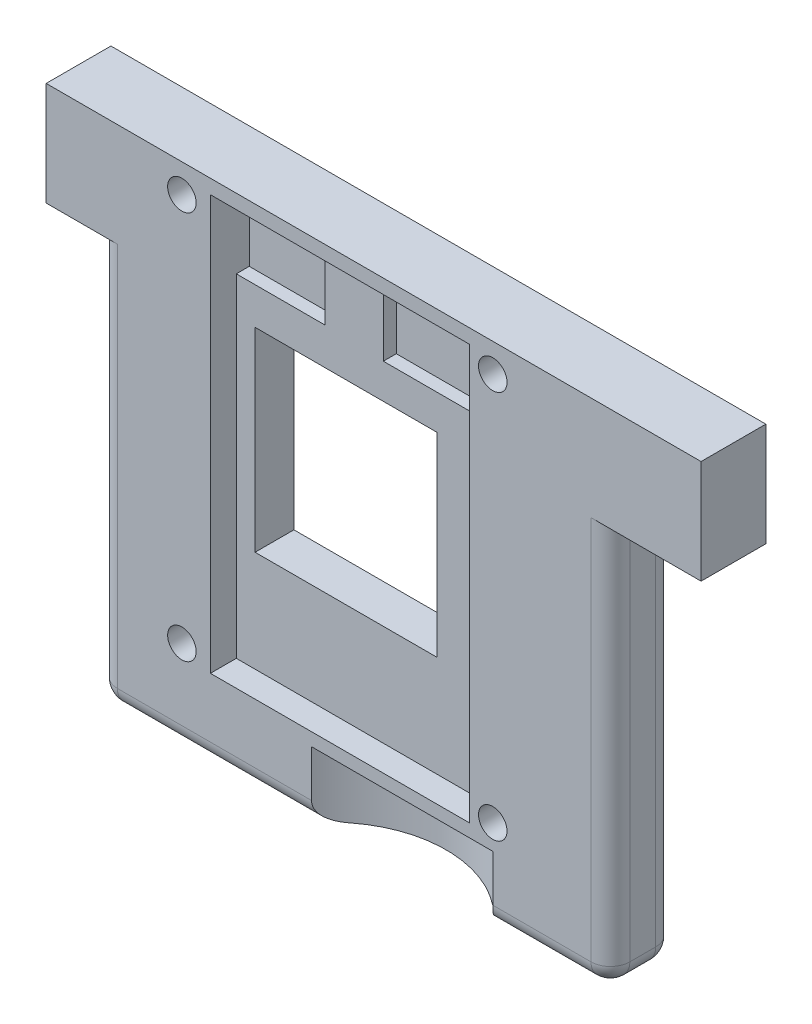
from build123d import *

# Parameters (mm, degrees)
SKETCH1_W               = 19.78
SKETCH1_H               = 22
BOSS_EXTRUDE1_DEPTH     = 2.5
SKETCH2_R               = 0.55
CUT_EXTRUDE1_DEPTH      = 2.5
SKETCH3_W               = 7.014228963
SKETCH3_H               = 7.519558389
CUT_EXTRUDE2_DEPTH      = 2.5
SKETCH4_W               = 10
SKETCH4_H               = 16
CUT_EXTRUDE3_DEPTH      = 1
SKETCH5_W               = 4.325292028
SKETCH5_H               = 2.74046394
SKETCH5_W_2             = 3.425085756
SKETCH5_H_2             = 3.145892333
CUT_EXTRUDE4_DEPTH      = 0.5
SKETCH6_R               = 4.45
CUT_EXTRUDE5_DEPTH      = 1.5
CUT_EXTRUDE5_DEPTH_BACK = 1.1
SKETCH7_W               = 19.78
SKETCH7_H               = 2.5
CUT_EXTRUDE6_DEPTH      = 2.4
SKETCH8_W               = 3.5
SKETCH8_H               = 4
SKETCH8_W_2             = 2
BOSS_EXTRUDE2_DEPTH     = 2.5
FILLET1_R               = 0.75


with BuildPart() as part:
    # Sketch1 → Boss-Extrude1 (new body)
    with BuildSketch(Plane.XY):
        with Locations((16.80685162, -7.939657117)):
            Rectangle(SKETCH1_W, SKETCH1_H)
    extrude(amount=BOSS_EXTRUDE1_DEPTH)

    # Sketch2 → Cut-Extrude1 (cut)
    with BuildSketch(Plane.XY.offset(2.5)):
        with Locations((22.156215749, -0.440049881)):
            Circle(SKETCH2_R)
        with Locations((22.156215749, -15.440049881)):
            Circle(SKETCH2_R)
        with Locations((10.156215749, -15.440049881)):
            Circle(SKETCH2_R)
        with Locations((10.156215749, -0.440049881)):
            Circle(SKETCH2_R)
    extrude(amount=-CUT_EXTRUDE1_DEPTH, mode=Mode.SUBTRACT)

    # Sketch3 → Cut-Extrude2 (cut)
    with BuildSketch(Plane.XY.offset(2.5)):
        with Locations((15.488045681, -8.221060457)):
            Rectangle(SKETCH3_W, SKETCH3_H)
    extrude(amount=-CUT_EXTRUDE2_DEPTH, mode=Mode.SUBTRACT)

    # Sketch4 → Cut-Extrude3 (cut)
    with BuildSketch(Plane.XY.offset(2.5)):
        with Locations((16.25685162, -7.889657117)):
            Rectangle(SKETCH4_W, SKETCH4_H)
    extrude(amount=-CUT_EXTRUDE3_DEPTH, mode=Mode.SUBTRACT)

    # Sketch5 → Cut-Extrude4 (cut)
    with BuildSketch(Plane.XY.offset(1.5)):
        with Locations((19.094205606, -1.748569373)):
            Rectangle(SKETCH5_W, SKETCH5_H)
        with Locations((12.969394498, -1.462603284)):
            Rectangle(SKETCH5_W_2, SKETCH5_H_2)
    extrude(amount=-CUT_EXTRUDE4_DEPTH, mode=Mode.SUBTRACT)

    # Sketch6 → Cut-Extrude5 (cut, two sides)
    with BuildSketch(Plane.XZ.offset(17.489657117)) as cut_extrude5_sk:
        with Locations((18.65685162, 5.25)):
            Circle(SKETCH6_R)
    extrude(amount=CUT_EXTRUDE5_DEPTH, mode=Mode.SUBTRACT)
    extrude(cut_extrude5_sk.sketch, amount=-CUT_EXTRUDE5_DEPTH_BACK, mode=Mode.SUBTRACT)

    # Sketch7 → Cut-Extrude6 (cut)
    with BuildSketch(Plane(origin=(0, 3.060342883, 0), x_dir=(1, 0, 0), z_dir=(0, 1, 0))):
        with Locations((16.80685162, -1.25)):
            Rectangle(SKETCH7_W, SKETCH7_H)
    extrude(amount=-CUT_EXTRUDE6_DEPTH, mode=Mode.SUBTRACT)

    # Sketch8 → Boss-Extrude2 (add)
    with BuildSketch(Plane.XY.offset(2.5)):
        with Locations((28.44685162, -1.339657117)):
            Rectangle(SKETCH8_W, SKETCH8_H)
        with Locations((5.91685162, -1.339657117)):
            Rectangle(SKETCH8_W_2, SKETCH8_H)
    extrude(amount=-BOSS_EXTRUDE2_DEPTH)

    # Fillet1
    fillet1_edges = [part.edges().sort_by_distance(p)[0] for p in [
        (6.91685162, -11.139657117, 0),
        (6.91685162, -11.139657117, 2.5),
        (11.037566052, -18.939657117, 2.5),
        (26.69685162, -11.139657117, 2.5),
        (16.80685162, -18.939657117, 0),
        (26.69685162, -11.139657117, 0),
        (26.69685162, -18.939657117, 1.25),
        (6.91685162, -18.939657117, 1.25),
        (24.426137189, -18.939657117, 2.5),
    ]]
    fillet(fillet1_edges, radius=FILLET1_R)


solid = part.part
